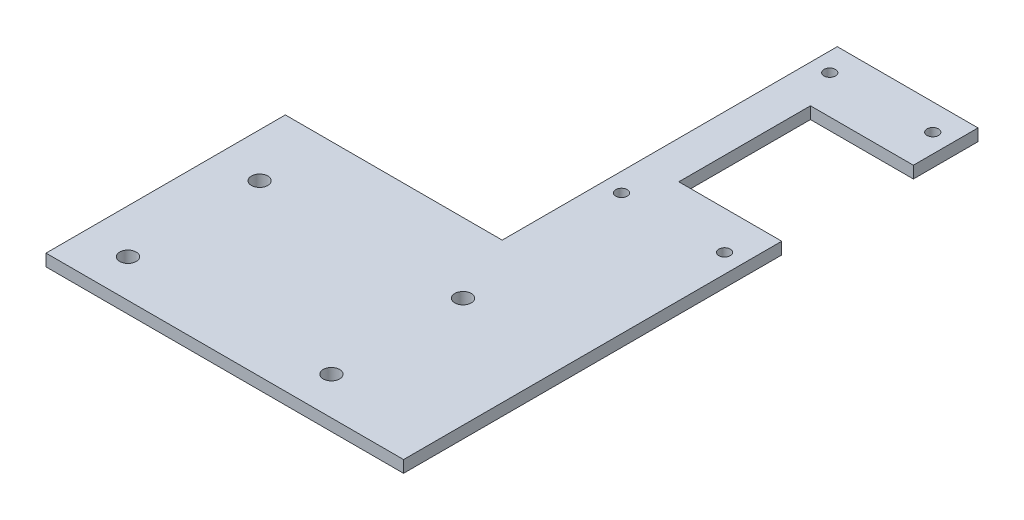
from build123d import *

# Parameters (mm, degrees)
SKETCH1_R           = 4.3688
SKETCH1_R_2         = 3.048
BOSS_EXTRUDE1_DEPTH = 6.35


with BuildPart() as part:
    # Sketch1 → Boss-Extrude1 (new body)
    with BuildSketch(Plane(origin=(0, 0, 0), x_dir=(1, 0, 0), z_dir=(0, 1, 0))):
        Polygon((152.4, 152.4), (77.73162, 152.4), (77.73162, -25.4), (-37.33419, -25.4), (-37.33419, -152.4), (152.4, -152.4), (152.4, 48.26), (97.79, 48.26), (97.79, 118.11), (152.4, 118.11), align=None)
        with Locations((-13.91158, -132.334)):
            Circle(SKETCH1_R, mode=Mode.SUBTRACT)
        with Locations((-13.91158, -62.484)):
            Circle(SKETCH1_R, mode=Mode.SUBTRACT)
        with Locations((94.03842, -132.334)):
            Circle(SKETCH1_R, mode=Mode.SUBTRACT)
        with Locations((94.03842, -62.484)):
            Circle(SKETCH1_R, mode=Mode.SUBTRACT)
        with Locations((87.68842, 27.94)):
            Circle(SKETCH1_R_2, mode=Mode.SUBTRACT)
        with Locations((142.367, 27.94)):
            Circle(SKETCH1_R_2, mode=Mode.SUBTRACT)
        with Locations((87.68842, 138.43)):
            Circle(SKETCH1_R_2, mode=Mode.SUBTRACT)
        with Locations((142.367, 138.43)):
            Circle(SKETCH1_R_2, mode=Mode.SUBTRACT)
    extrude(amount=BOSS_EXTRUDE1_DEPTH)


solid = part.part
